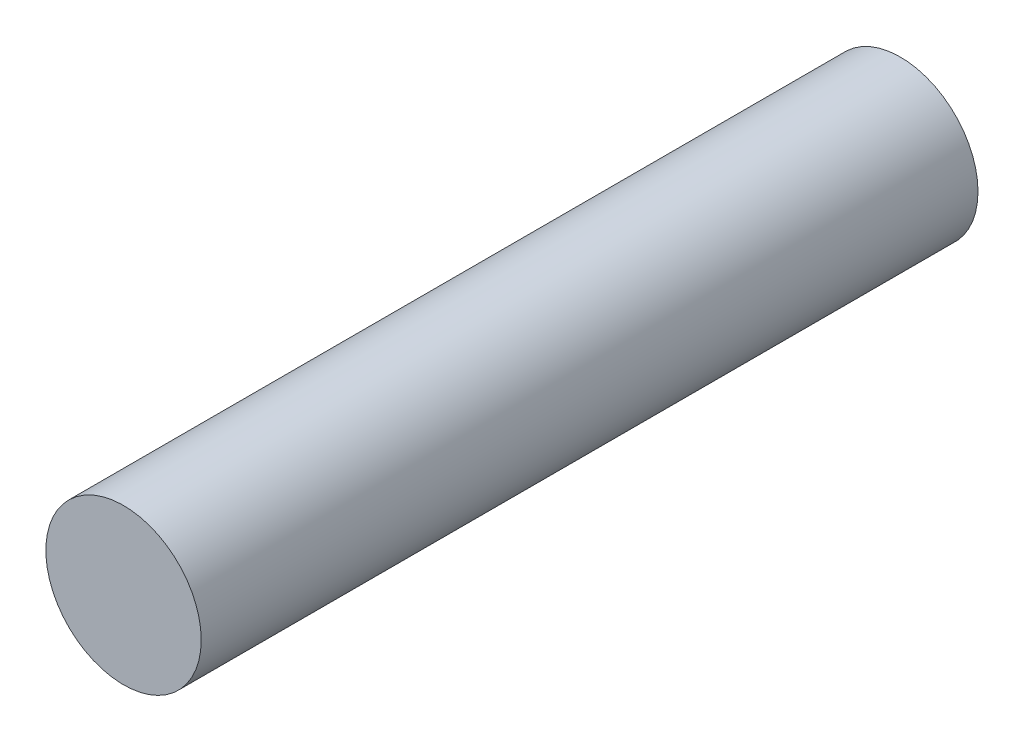
from build123d import *

# Parameters (mm, degrees)
ESBO_O1_R                = 5
RESSALTO_EXTRUS_O1_DEPTH = 50


with BuildPart() as part:
    # Esboço1 → Ressalto-extrusão1 (new body)
    with BuildSketch(Plane.XY):
        Circle(ESBO_O1_R)
    extrude(amount=RESSALTO_EXTRUS_O1_DEPTH)


solid = part.part
